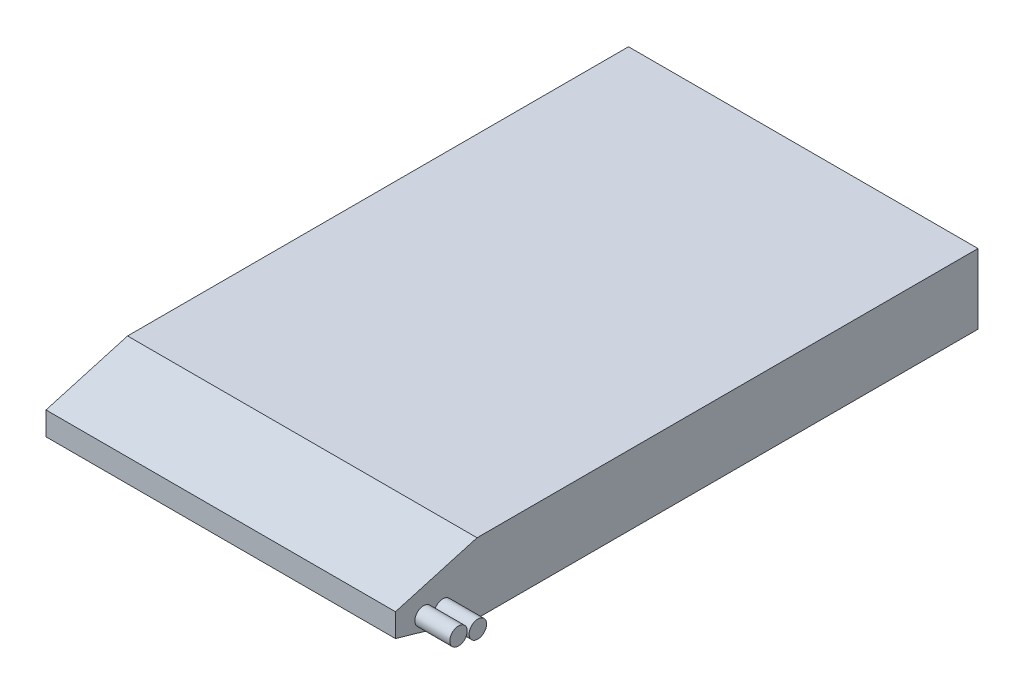
from build123d import *

# Parameters (mm, degrees)
SKETCH1_W           = 30
SKETCH1_H           = 50
BOSS_EXTRUDE1_DEPTH = 6
CHAMFER1_SIZE       = 2
CHAMFER1_SIZE2      = 7
SKETCH2_R           = 0.75
BOSS_EXTRUDE2_DEPTH = 3


with BuildPart() as part:
    # Sketch1 → Boss-Extrude1 (new body)
    with BuildSketch(Plane(origin=(0, 0, 0), x_dir=(1, 0, 0), z_dir=(0, 1, 0))):
        Rectangle(SKETCH1_W, SKETCH1_H)
    extrude(amount=BOSS_EXTRUDE1_DEPTH)

    # Chamfer1
    chamfer1_edges = [part.edges().sort_by_distance(p)[0] for p in [
        (0, 0, 25),
        (0, 6, 25),
    ]]
    chamfer1_side = [part.faces().sort_by_distance(p)[0] for p in [
        (0, 3, 25),
    ]]
    chamfer(chamfer1_edges, length=CHAMFER1_SIZE, length2=CHAMFER1_SIZE2, reference=chamfer1_side[0])

    # Sketch2 → Boss-Extrude2 (add)
    with BuildSketch(Plane(origin=(15, 0, 0), x_dir=(0, 0, -1), z_dir=(1, 0, 0))):
        with Locations((-22.591828887, 2.491974932)):
            Circle(SKETCH2_R)
        with Locations((-20.930691136, 2.177979382)):
            Circle(SKETCH2_R)
    extrude(amount=BOSS_EXTRUDE2_DEPTH)


solid = part.part
